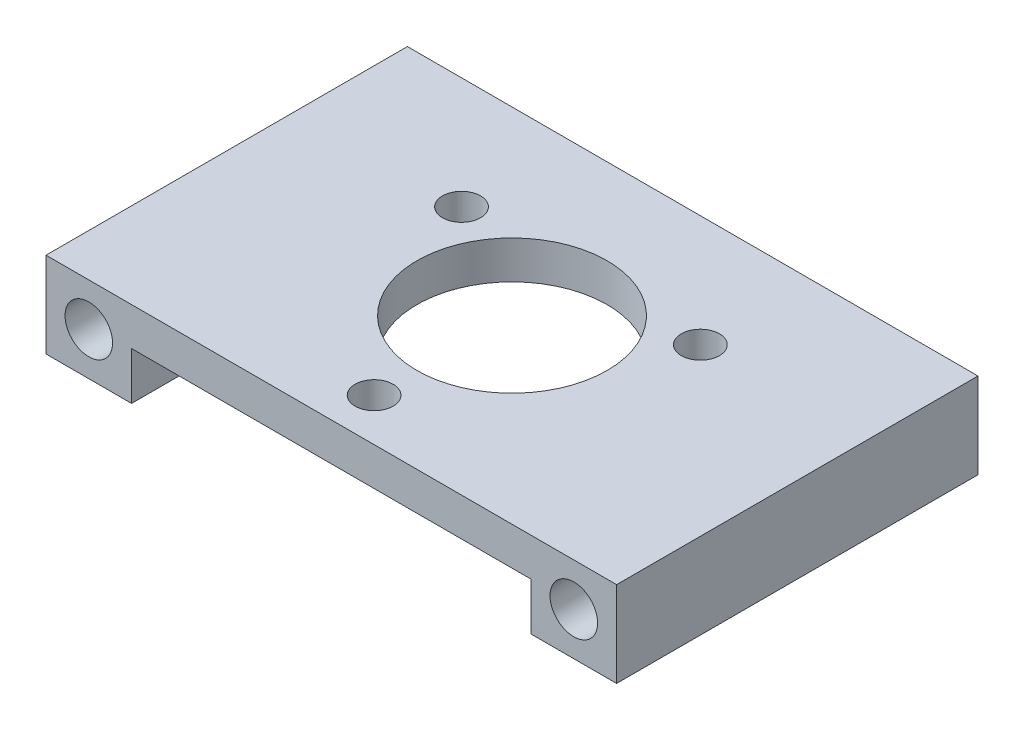
from build123d import *

# Parameters (mm, degrees)
SKETCH1_R           = 2.5
BOSS_EXTRUDE1_DEPTH = 38
SKETCH2_R           = 10
SKETCH2_R_2         = 2
CUT_EXTRUDE1_DEPTH  = 38


with BuildPart() as part:
    # Sketch1 → Boss-Extrude1 (new body)
    with BuildSketch(Plane.XY):
        Polygon((-30, 0), (-30, -9), (-21, -9), (-21, -4), (21, -4), (21, -9), (30, -9), (30, 0), align=None)
        with Locations((-25.5, -4.5)):
            Circle(SKETCH1_R, mode=Mode.SUBTRACT)
        with Locations((25.5, -4.5)):
            Circle(SKETCH1_R, mode=Mode.SUBTRACT)
    extrude(amount=BOSS_EXTRUDE1_DEPTH)

    # Sketch2 → Cut-Extrude1 (cut)
    with BuildSketch(Plane.XZ.offset(4)):
        with Locations((0, 19)):
            Circle(SKETCH2_R)
        with Locations((0, 33.5)):
            Circle(SKETCH2_R_2)
        with Locations((12.557368355, 11.75)):
            Circle(SKETCH2_R_2)
        with Locations((-12.557368355, 11.75)):
            Circle(SKETCH2_R_2)
    extrude(amount=-CUT_EXTRUDE1_DEPTH, mode=Mode.SUBTRACT)


solid = part.part
